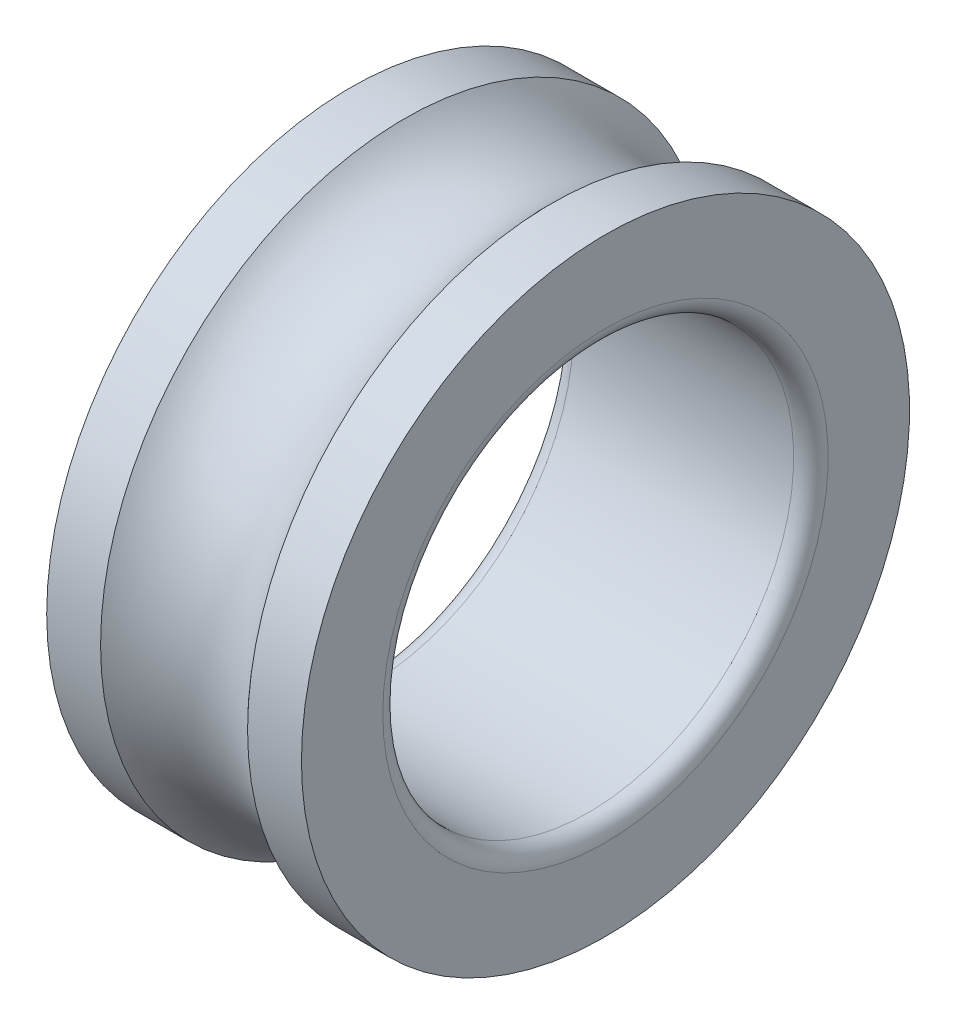
from build123d import *


with BuildPart() as part:
    # Sketch1 → Revolve1 (revolve)
    with BuildSketch(Plane.XY):
        with BuildLine():
            Line((-15.5, 37), (-8.94427191, 37))
            ThreePointArc((-8.94427191, 37), (0, 33), (8.94427191, 37))
            Line((8.94427191, 37), (15.5, 37))
            Line((15.5, 37), (15.5, 27.1))
            ThreePointArc((15.5, 27.1), (14.88492424, 25.61507576), (13.4, 25))
            Line((13.4, 25), (-13.4, 25))
            ThreePointArc((-13.4, 25), (-14.88492424, 25.61507576), (-15.5, 27.1))
            Line((-15.5, 27.1), (-15.5, 37))
        make_face()
    revolve(axis=Axis((-12.261894954, 0, 0), (1, 0, 0)))


solid = part.part
